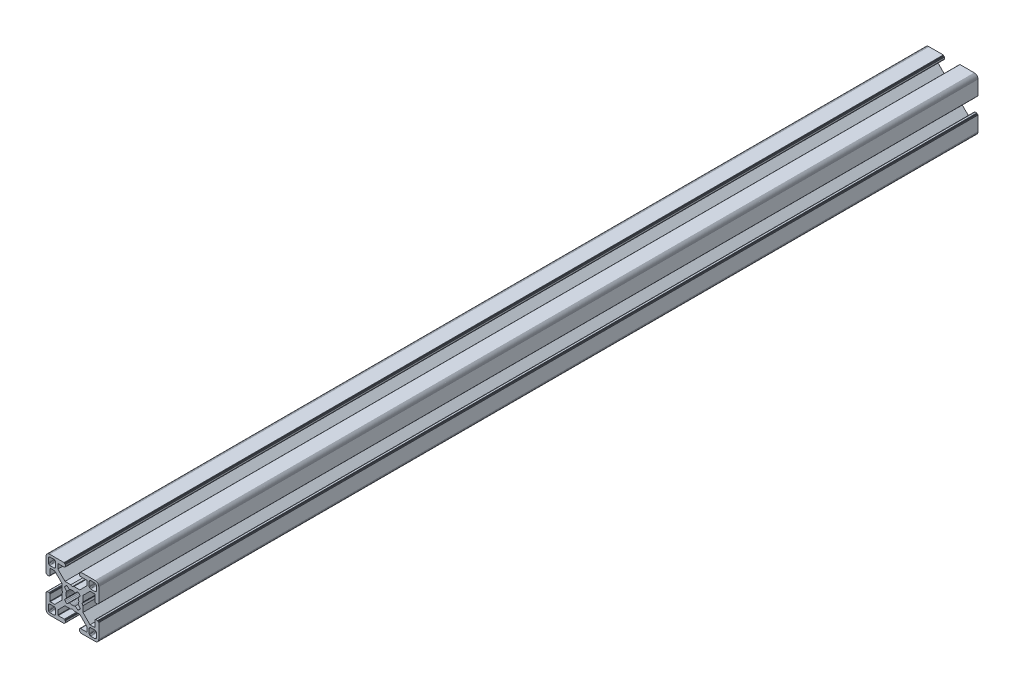
from build123d import *

# Parameters (mm, degrees)
BOSS_EXTRUDE1_DEPTH = 500


with BuildPart() as part:
    # Sketch1 → Boss-Extrude1 (new body)
    with BuildSketch(Plane.XY):
        Polygon((28.34729664, 29.969613999), (28.000000864, 29.999999329), (19.750000909, 29.999999329), (19.715268165, 29.996961355), (19.681595266, 29.987938702), (19.649999216, 29.973205179), (19.621443003, 29.953207821), (19.596790895, 29.928557575), (19.576793537, 29.899999499), (19.562061876, 29.868405312), (19.55303736, 29.834728688), (19.549999386, 29.799999669), (19.549999386, 29.699999839), (19.546961412, 29.665268958), (19.537936896, 29.631596059), (19.523203373, 29.599998146), (19.503207877, 29.571441934), (19.478557631, 29.546789825), (19.449999556, 29.526794329), (19.418403506, 29.512060806), (19.384728745, 29.503038153), (19.349999726, 29.500000179), (19.249999896, 29.500000179), (19.215267517, 29.496958527), (19.181592755, 29.487935874), (19.149996706, 29.47320235), (19.12143863, 29.453206855), (19.096788384, 29.428554746), (19.076791026, 29.399996671), (19.062057503, 29.368402484), (19.05303485, 29.334725859), (19.049996876, 29.299998703), (19.049996876, 28.39999837), (19.059110798, 28.29580945), (19.08618062, 28.194785165), (19.13038119, 28.099997016), (19.190369539, 28.014324653), (19.264324002, 27.94037019), (19.349996366, 27.88038184), (19.444784515, 27.836181271), (19.545806937, 27.809111449), (19.650010894, 27.799984574), (23.050010706, 27.799984574), (23.084741588, 27.7969466), (23.118414487, 27.787923946), (23.150012399, 27.773190423), (23.178568612, 27.753193065), (23.203220721, 27.728542819), (23.223218079, 27.699984744), (23.237949739, 27.668386831), (23.246974255, 27.634713932), (23.25001142, 27.59998608), (23.25001142, 25.049987618), (19.204474482, 20.999982084), (15.900007876, 20.999982084), (15.000008474, 20.48483404), (14.10000814, 20.999982084), (10.795543398, 20.999982084), (7.997342887, 23.801274731), (6.750011387, 25.049984589), (6.750011387, 27.599983051), (6.753049362, 27.634713932), (6.762072946, 27.668386831), (6.776805538, 27.699984744), (6.796801965, 27.728542819), (6.821454073, 27.753193065), (6.850011218, 27.773190423), (6.881607267, 27.787923946), (6.915282029, 27.7969466), (6.950011048, 27.799984574), (10.350011791, 27.799984574), (10.45420071, 27.809098497), (10.555223133, 27.836168318), (10.650011282, 27.880368888), (10.735683645, 27.940357238), (10.809638108, 28.014311701), (10.869626458, 28.099984064), (10.913827027, 28.194772213), (10.940895918, 28.295796498), (10.950010772, 28.399985417), (10.950010772, 29.299985751), (10.946974575, 29.334739239), (10.93795065, 29.368415522), (10.923215933, 29.400009153), (10.903218427, 29.428566473), (10.878566319, 29.45321765), (10.849999264, 29.473204166), (10.818403214, 29.487937689), (10.784728453, 29.496960342), (10.749999434, 29.500000179), (10.649999604, 29.500000179), (10.615270585, 29.503038153), (10.581595823, 29.512060806), (10.549999774, 29.526794329), (10.521441698, 29.546789825), (10.496791452, 29.571441934), (10.476795025, 29.599998146), (10.462061502, 29.631596059), (10.453037918, 29.665268958), (10.449999943, 29.699999839), (10.449999943, 29.799999669), (10.446961969, 29.834728688), (10.437938385, 29.868405312), (10.423205793, 29.899999499), (10.403208435, 29.928557575), (10.378557257, 29.953207821), (10.350000113, 29.973205179), (10.318404064, 29.987938702), (10.284729302, 29.996961355), (10.250000283, 29.999999329), (1.999999397, 29.999999329), (1.652702689, 29.969613999), (1.315958682, 29.879383743), (0.999999233, 29.732050374), (0.714424066, 29.532089829), (0.467910431, 29.285576195), (0.267948955, 28.999999166), (0.120614655, 28.684040532), (0.030384399, 28.34729664), (0, 28.000000864), (0, 19.750000909), (0.003037974, 19.715268165), (0.012061559, 19.681595266), (0.026795082, 19.649999216), (0.046790577, 19.621441141), (0.071442686, 19.596789032), (0.09999983, 19.576793537), (0.13159588, 19.562060013), (0.165270641, 19.55303736), (0.19999966, 19.549999386), (0.299999461, 19.549999386), (0.334728509, 19.546959549), (0.368403242, 19.537936896), (0.399999321, 19.523203373), (0.428556465, 19.503207877), (0.453208573, 19.478555769), (0.473204069, 19.449997693), (0.487937592, 19.418403506), (0.496961176, 19.384728745), (0.499999151, 19.349999726), (0.499999151, 19.249998033), (0.503038056, 19.215269014), (0.512060709, 19.181594253), (0.526794232, 19.150000066), (0.546790194, 19.121441524), (0.571441837, 19.096789882), (0.60000029, 19.076794925), (0.631595686, 19.062061999), (0.665270619, 19.053039982), (0.700000626, 19.050000801), (1.60000096, 19.050000801), (1.704189879, 19.059116587), (1.805213233, 19.086186409), (1.90000045, 19.130385115), (1.985673745, 19.190375328), (2.059627277, 19.264327928), (2.119616325, 19.350002154), (2.163816196, 19.444788441), (2.190886018, 19.545812726), (2.200000872, 19.650001645), (2.200000872, 23.050001457), (2.203039777, 23.084732338), (2.212062431, 23.118405237), (2.226795954, 23.15000315), (2.246792381, 23.178559362), (2.271443558, 23.203211471), (2.300000702, 23.223206967), (2.331596752, 23.23794049), (2.365271513, 23.246965006), (2.400001464, 23.250001117), (4.950000857, 23.250001117), (7.997332093, 20.202670812), (8.995535423, 19.204467788), (8.995535423, 15.900001182), (9.515148227, 15.00000178), (8.995535423, 14.100002378), (8.995535423, 10.795536704), (4.950000857, 6.750002138), (2.400001464, 6.750002138), (2.365271513, 6.753040112), (2.331596752, 6.762063697), (2.300000702, 6.77679722), (2.271443558, 6.796793647), (2.246792381, 6.821444824), (2.226795954, 6.850001968), (2.212062431, 6.881598018), (2.203039777, 6.915272779), (2.200000872, 6.950002729), (2.200000872, 10.350002542), (2.190896812, 10.454174265), (2.16382699, 10.555197618), (2.119627119, 10.649984836), (2.059638071, 10.735658131), (1.985684539, 10.809611663), (1.900011244, 10.869600944), (1.805224027, 10.913800582), (1.704200673, 10.940870404), (1.600011754, 10.949986189), (0.70001142, 10.949986189), (0.665281355, 10.946948596), (0.631606253, 10.937926283), (0.600010578, 10.923193954), (0.571451747, 10.903199537), (0.546799638, 10.87854836), (0.526794232, 10.850000195), (0.512060709, 10.818404146), (0.503038056, 10.784730315), (0.499999151, 10.750000365), (0.499999151, 10.650000535), (0.496961176, 10.615270585), (0.487937592, 10.581596754), (0.473204069, 10.550000705), (0.453208573, 10.521443561), (0.428556465, 10.496791452), (0.399999321, 10.476795956), (0.368403242, 10.462062433), (0.334728509, 10.453038849), (0.299999461, 10.449999943), (0.19999966, 10.449999943), (0.165270641, 10.446961969), (0.13159588, 10.437939316), (0.09999983, 10.423205793), (0.071442686, 10.403209366), (0.046790577, 10.378558189), (0.026795082, 10.350000113), (0.012061559, 10.318404064), (0.003037974, 10.284729302), (0, 10.250000283), (0, 1.999999397), (0.030384399, 1.652702689), (0.120614655, 1.315958682), (0.267948955, 0.999999233), (0.467910431, 0.714424066), (0.714424066, 0.467910431), (0.999999233, 0.267948955), (1.315958682, 0.120614655), (1.652702689, 0.030384399), (1.999999397, 0), (10.250000283, 0), (10.284729302, 0.003037974), (10.318404064, 0.012061559), (10.350000113, 0.026795082), (10.378557257, 0.046790577), (10.403208435, 0.071442686), (10.423205793, 0.09999983), (10.437938385, 0.13159588), (10.446961969, 0.165270641), (10.449999943, 0.19999966), (10.449999943, 0.300000422), (10.453037918, 0.334729441), (10.462061502, 0.368404202), (10.476795025, 0.400000252), (10.496791452, 0.428557396), (10.521441698, 0.453208573), (10.549999774, 0.473205), (10.581595823, 0.487938523), (10.615270585, 0.496961176), (10.649999604, 0.500000082), (10.749999434, 0.500000082), (10.784728453, 0.503038056), (10.818403214, 0.512060709), (10.849999264, 0.526794232), (10.878547894, 0.546800104), (10.903198606, 0.571451747), (10.923194493, 0.6000102), (10.93792742, 0.631606528), (10.946949437, 0.66528146), (10.950010772, 0.699984975), (10.950010772, 1.599985308), (10.940895918, 1.704174228), (10.913827027, 1.805197581), (10.869626458, 1.89998573), (10.809638108, 1.985658094), (10.735683645, 2.059612557), (10.650011282, 2.119600674), (10.555223133, 2.163801476), (10.45420071, 2.190870367), (10.350011791, 2.199985221), (6.950011048, 2.199985221), (6.915282029, 2.203024126), (6.881607267, 2.212046779), (6.850011218, 2.226780302), (6.821454073, 2.246776729), (6.796801965, 2.271427907), (6.776805538, 2.299985982), (6.762072946, 2.331582032), (6.753049362, 2.365256793), (6.750011387, 2.399985812), (6.750011387, 4.949985206), (9.787457566, 7.990785077), (10.795545277, 8.999985833), (14.100010019, 8.999985833), (15.000010353, 9.515133877), (15.900009756, 8.999985833), (19.204476361, 8.999985833), (20.21256413, 7.990786065), (23.25001142, 4.949988235), (23.25001142, 2.399988841), (23.246974255, 2.365256793), (23.237949739, 2.331582032), (23.223218079, 2.299985982), (23.203220721, 2.271427907), (23.178568612, 2.246776729), (23.150012399, 2.226780302), (23.118414487, 2.212046779), (23.084741588, 2.203024126), (23.050010706, 2.199985221), (19.650010894, 2.199985221), (19.545806937, 2.190883319), (19.444784515, 2.163814428), (19.349996366, 2.119613626), (19.264324002, 2.059625509), (19.190369539, 1.985671046), (19.13038119, 1.899998682), (19.08618062, 1.805210533), (19.059110798, 1.70418718), (19.049996876, 1.599998261), (19.049996876, 0.699997927), (19.053035506, 0.665268966), (19.062058795, 0.631594374), (19.076792915, 0.599998603), (19.096790813, 0.571440905), (19.121441524, 0.546790194), (19.149999978, 0.526794306), (19.181596306, 0.51206138), (19.215271238, 0.503039363), (19.249999896, 0.500000082), (19.349999726, 0.500000082), (19.384728745, 0.496961176), (19.418403506, 0.487938523), (19.449999556, 0.473205), (19.478557631, 0.453208573), (19.503207877, 0.428557396), (19.523203373, 0.400000252), (19.537936896, 0.368404202), (19.546961412, 0.334729441), (19.549999386, 0.300000422), (19.549999386, 0.19999966), (19.55303736, 0.165270641), (19.562061876, 0.13159588), (19.576793537, 0.09999983), (19.596789964, 0.071441755), (19.621442072, 0.046789646), (19.649998285, 0.02679415), (19.681594335, 0.012060627), (19.715267234, 0.003037043), (19.750000909, 0), (28.000000864, 0), (28.34729664, 0.030384399), (28.684040532, 0.120614655), (28.999999166, 0.267948955), (29.285576195, 0.467910431), (29.532089829, 0.714424066), (29.732050374, 0.999999233), (29.879383743, 1.315958682), (29.969613999, 1.652702689), (29.999999329, 1.999999397), (29.999999329, 10.250000283), (29.996974806, 10.284715361), (29.987951516, 10.318389952), (29.973217396, 10.349985723), (29.953219499, 10.378543421), (29.928568787, 10.403194133), (29.899999499, 10.423205793), (29.868405312, 10.437939316), (29.834728688, 10.446961969), (29.799999669, 10.449999943), (29.699999839, 10.449999943), (29.664909937, 10.453400043), (29.631233313, 10.462423628), (29.599637263, 10.477157151), (29.57108105, 10.497152646), (29.546427079, 10.521804755), (29.526433446, 10.550361899), (29.511699923, 10.581957949), (29.502675407, 10.615631779), (29.499637433, 10.650361729), (29.499637433, 10.750361559), (29.49697202, 10.784715548), (29.487949367, 10.818389378), (29.473215844, 10.849985428), (29.453220348, 10.878542572), (29.428568239, 10.90319468), (29.400010164, 10.923190176), (29.368415977, 10.937923699), (29.334741215, 10.946947284), (29.300012197, 10.949986189), (28.400011863, 10.949986189), (28.29581215, 10.9408876), (28.194787865, 10.913817778), (28.099999716, 10.86961814), (28.014327352, 10.809628859), (27.940374752, 10.735675327), (27.880384539, 10.650002032), (27.836185833, 10.555214814), (27.809114148, 10.454191461), (27.800000225, 10.350002542), (27.800000225, 6.950002729), (27.796962251, 6.915272779), (27.787939598, 6.881598018), (27.773206075, 6.850001968), (27.753208716, 6.821444824), (27.728558471, 6.796793647), (27.700000395, 6.77679722), (27.668404345, 6.762063697), (27.634729584, 6.753040112), (27.599998702, 6.750002138), (25.05000024, 6.750002138), (23.809199132, 7.99080223), (21.004464477, 10.795534588), (21.004464477, 14.100000262), (20.484851673, 14.999999665), (21.004464477, 15.899999067), (21.004464477, 19.204465672), (25.05000024, 23.250001117), (27.599998702, 23.250001117), (27.634729584, 23.246965006), (27.668404345, 23.23794049), (27.700000395, 23.223206967), (27.728558471, 23.203211471), (27.753208716, 23.178559362), (27.773206075, 23.15000315), (27.787939598, 23.118405237), (27.796962251, 23.084732338), (27.800000225, 23.050001457), (27.800000225, 19.650001645), (27.809114148, 19.545812726), (27.836185833, 19.444788441), (27.880384539, 19.350002154), (27.940370508, 19.264323684), (28.014323108, 19.190371084), (28.099995472, 19.130380872), (28.194783621, 19.086182165), (28.295807906, 19.059112343), (28.400001069, 19.050000801), (29.300001402, 19.050000801), (29.334730421, 19.053040638), (29.368405183, 19.062063291), (29.39999937, 19.076796814), (29.42819671, 19.097149726), (29.452848353, 19.1218023), (29.472843309, 19.150360754), (29.487576235, 19.181955219), (29.496598252, 19.215630151), (29.499637433, 19.250359227), (29.499637433, 19.35036092), (29.502675407, 19.385089939), (29.511699923, 19.4187647), (29.526433446, 19.450358887), (29.546427079, 19.478916963), (29.57108105, 19.503569071), (29.599637263, 19.523564567), (29.631233313, 19.53829809), (29.664909937, 19.547320743), (29.699999839, 19.549999386), (29.799999669, 19.549999386), (29.834728688, 19.55303736), (29.868405312, 19.562060013), (29.899999499, 19.576793537), (29.928557575, 19.596789032), (29.953207821, 19.621441141), (29.973205179, 19.649999216), (29.987938702, 19.681595266), (29.996961355, 19.715268165), (29.999999329, 19.750000909), (29.999999329, 28.000000864), (29.969613999, 28.34729664), (29.879383743, 28.684040532), (29.732050374, 28.999999166), (29.532089829, 29.285576195), (29.285576195, 29.532089829), (28.999999166, 29.732050374), (28.684040532, 29.879383743), align=None)
        Polygon((1.299998723, 25.499999523), (1.299998723, 27.699999511), (1.312309876, 27.856435627), (1.348942518, 28.009016067), (1.408992335, 28.153989464), (1.490981318, 28.287785128), (1.592892222, 28.407108039), (1.71221327, 28.50901708), (1.846008119, 28.591006994), (1.9909814, 28.651056811), (2.143563703, 28.687689453), (2.299998887, 28.699999675), (4.499998875, 28.699999675), (4.656434059, 28.687689453), (4.809016362, 28.651056811), (4.953989759, 28.591006994), (5.087784491, 28.50901708), (5.207106471, 28.407108039), (5.309016444, 28.287785128), (5.391005427, 28.153989464), (5.451056175, 28.009016067), (5.487687886, 27.856435627), (5.499999039, 27.699999511), (5.499999039, 25.499999523), (5.487687886, 25.34356527), (5.451056175, 25.190982968), (5.391005427, 25.04600957), (5.309016444, 24.912213907), (5.207106471, 24.792892858), (5.087784491, 24.690981954), (4.953989759, 24.60899204), (4.809016362, 24.548944086), (4.656434059, 24.512309581), (4.499998875, 24.499999359), (2.299998887, 24.499999359), (2.143563703, 24.512309581), (1.9909814, 24.548944086), (1.846008119, 24.60899204), (1.71221327, 24.690981954), (1.592892222, 24.792892858), (1.490981318, 24.912213907), (1.408992335, 25.04600957), (1.348942518, 25.190982968), (1.312309876, 25.34356527), align=None, mode=Mode.SUBTRACT)
        Polygon((25.34356527, 28.687689453), (25.499999523, 28.699999675), (27.699999511, 28.699999675), (27.856435627, 28.687689453), (28.009017929, 28.651056811), (28.153991327, 28.591006994), (28.28778699, 28.50901708), (28.407108039, 28.407108039), (28.50901708, 28.287785128), (28.591006994, 28.153989464), (28.651056811, 28.009016067), (28.687689453, 27.856435627), (28.700001538, 27.699999511), (28.700001538, 25.499999523), (28.687689453, 25.34356527), (28.651056811, 25.190982968), (28.591006994, 25.04600957), (28.50901708, 24.912213907), (28.407108039, 24.792892858), (28.28778699, 24.690981954), (28.153991327, 24.60899204), (28.009017929, 24.548944086), (27.856435627, 24.512309581), (27.699999511, 24.499999359), (25.499999523, 24.499999359), (25.34356527, 24.512309581), (25.190982968, 24.548944086), (25.04600957, 24.60899204), (24.912215769, 24.690981954), (24.792892858, 24.792892858), (24.690981954, 24.912213907), (24.608993903, 25.04600957), (24.548944086, 25.190982968), (24.512311444, 25.34356527), (24.500001222, 25.499999523), (24.500001222, 27.699999511), (24.512311444, 27.856435627), (24.548944086, 28.009016067), (24.608993903, 28.153989464), (24.690981954, 28.287785128), (24.792892858, 28.407108039), (24.912215769, 28.50901708), (25.04600957, 28.591006994), (25.190982968, 28.651056811), align=None, mode=Mode.SUBTRACT)
        Polygon((14.999999665, 18.649999052), (15.550030395, 18.608318642), (16.087498516, 18.484227359), (16.600128263, 18.280562013), (18.13592948, 19.518401474), (18.644984812, 19.11874488), (19.103571773, 18.662061542), (19.505336881, 18.154669553), (18.280562013, 16.600130126), (18.484227359, 16.087498516), (18.608318642, 15.550030395), (18.649999052, 14.999999665), (18.608318642, 14.449968934), (18.484227359, 13.912500814), (18.280562013, 13.399870135), (19.505336881, 11.845329776), (19.103571773, 11.337937787), (18.644984812, 10.881252587), (18.13592948, 10.481598787), (16.600128263, 11.719437316), (16.087498516, 11.515771039), (15.550030395, 11.391680688), (14.999999665, 11.349999346), (14.449968934, 11.391680688), (13.912500814, 11.515771039), (13.399870135, 11.719437316), (11.864069849, 10.481598787), (11.355013587, 10.881252587), (10.896427557, 11.337937787), (10.494662449, 11.845329776), (11.719438247, 13.399870135), (11.515771039, 13.912500814), (11.391680688, 14.449968934), (11.349999346, 14.999999665), (11.391680688, 15.550030395), (11.515771039, 16.087498516), (11.719438247, 16.600130126), (10.494662449, 18.154669553), (10.896427557, 18.662061542), (11.355013587, 19.11874488), (11.864069849, 19.518401474), (13.399870135, 18.280562013), (13.912500814, 18.484227359), (14.449968934, 18.608318642), align=None, mode=Mode.SUBTRACT)
        Polygon((4.499998875, 1.299999771), (2.299998887, 1.299999771), (2.143563703, 1.312310807), (1.9909814, 1.348942518), (1.846008119, 1.408992335), (1.71221327, 1.490982249), (1.592892222, 1.592892222), (1.490981318, 1.712214202), (1.408992335, 1.846008934), (1.348942518, 1.990982331), (1.312309876, 2.143564634), (1.299998723, 2.299998887), (1.299998723, 4.499999806), (1.312309876, 4.656434059), (1.348942518, 4.809017293), (1.408992335, 4.95399069), (1.490981318, 5.087785423), (1.592892222, 5.207106471), (1.71221327, 5.309017375), (1.846008119, 5.391006358), (1.9909814, 5.451056175), (2.143563703, 5.487688817), (2.299998887, 5.49999997), (4.499998875, 5.49999997), (4.656434059, 5.487688817), (4.809016362, 5.451056175), (4.953989759, 5.391006358), (5.087784491, 5.309017375), (5.207106471, 5.207106471), (5.309016444, 5.087785423), (5.391005427, 4.95399069), (5.451056175, 4.809017293), (5.487687886, 4.656434059), (5.499999039, 4.499999806), (5.499999039, 2.299998887), (5.487687886, 2.143564634), (5.451056175, 1.990982331), (5.391005427, 1.846008934), (5.309016444, 1.712214202), (5.207106471, 1.592892222), (5.087784491, 1.490982249), (4.953989759, 1.408992335), (4.809016362, 1.348942518), (4.656434059, 1.312310807), align=None, mode=Mode.SUBTRACT)
        Polygon((27.699999511, 1.299999771), (25.499999523, 1.299999771), (25.34356527, 1.312310807), (25.190982968, 1.348942518), (25.04600957, 1.408992335), (24.912215769, 1.490982249), (24.792892858, 1.592892222), (24.690981954, 1.712214202), (24.608993903, 1.846008934), (24.548944086, 1.990982331), (24.512311444, 2.143564634), (24.500001222, 2.299998887), (24.500001222, 4.499999806), (24.512311444, 4.656434059), (24.548944086, 4.809017293), (24.608993903, 4.95399069), (24.690981954, 5.087785423), (24.792892858, 5.207106471), (24.912215769, 5.309017375), (25.04600957, 5.391006358), (25.190982968, 5.451056175), (25.34356527, 5.487688817), (25.499999523, 5.49999997), (27.699999511, 5.49999997), (27.856435627, 5.487688817), (28.009017929, 5.451056175), (28.153991327, 5.391006358), (28.28778699, 5.309017375), (28.407108039, 5.207106471), (28.50901708, 5.087785423), (28.591006994, 4.95399069), (28.651056811, 4.809017293), (28.687689453, 4.656434059), (28.700001538, 4.499999806), (28.700001538, 2.299998887), (28.687689453, 2.143564634), (28.651056811, 1.990982331), (28.591006994, 1.846008934), (28.50901708, 1.712214202), (28.407108039, 1.592892222), (28.28778699, 1.490982249), (28.153991327, 1.408992335), (28.009017929, 1.348942518), (27.856435627, 1.312310807), align=None, mode=Mode.SUBTRACT)
    extrude(amount=-BOSS_EXTRUDE1_DEPTH)


solid = part.part
